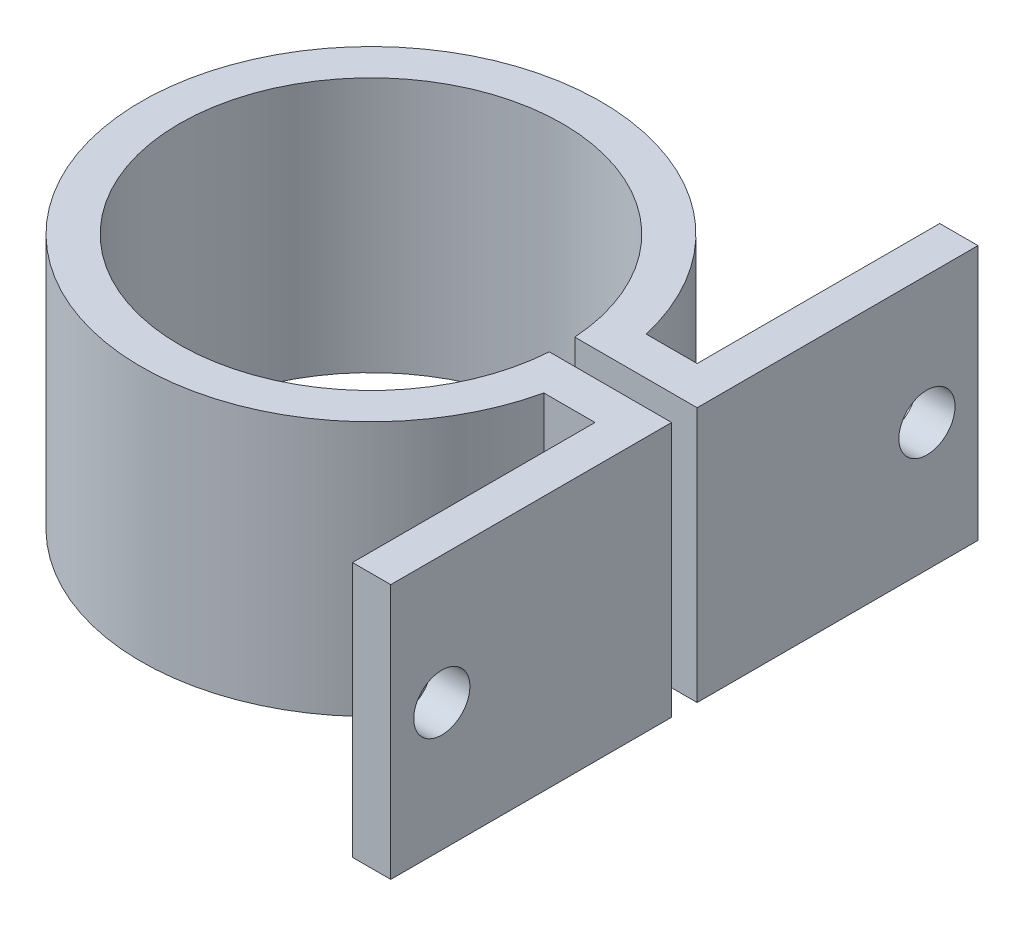
from build123d import *

# Parameters (mm, degrees)
BOSS_EXTRUDE1_DEPTH = 20
SKETCH2_R           = 2.2
CUT_EXTRUDE1_DEPTH  = 3


with BuildPart() as part:
    # Sketch1 → Boss-Extrude1 (new body)
    with BuildSketch(Plane(origin=(0, 0, 0), x_dir=(1, 0, 0), z_dir=(0, 1, 0))):
        with BuildLine():
            Line((24.549928775, -5.633868186), (24.549928775, -1))
            Line((24.549928775, -1), (14.966629547, -1))
            ThreePointArc((14.966629547, -1), (-15, 0), (14.966629547, 1))
            Line((14.966629547, 1), (24.549928775, 1))
            Line((24.549928775, 1), (24.549928775, 9.723102863))
            Line((24.549928775, 9.723102863), (24.549928775, 23))
            Line((24.549928775, 23), (21.549928775, 23))
            Line((21.549928775, 23), (21.549928775, 4))
            Line((21.549928775, 4), (17.549928775, 4))
            ThreePointArc((17.549928775, 4), (-18, 0), (17.549928775, -4))
            Line((17.549928775, -4), (21.549928775, -4))
            Line((21.549928775, -4), (21.549928775, -23))
            Line((21.549928775, -23), (24.549928775, -23))
            Line((24.549928775, -23), (24.549928775, -5.633868186))
        make_face()
    extrude(amount=BOSS_EXTRUDE1_DEPTH)

    # Sketch2 → Cut-Extrude1 (cut)
    with BuildSketch(Plane(origin=(24.549928775, 0, 0), x_dir=(0, 0, -1), z_dir=(1, 0, 0))):
        with Locations((19, 10)):
            Circle(SKETCH2_R)
        with Locations((-19, 10)):
            Circle(SKETCH2_R)
    extrude(amount=-CUT_EXTRUDE1_DEPTH, mode=Mode.SUBTRACT)


solid = part.part
